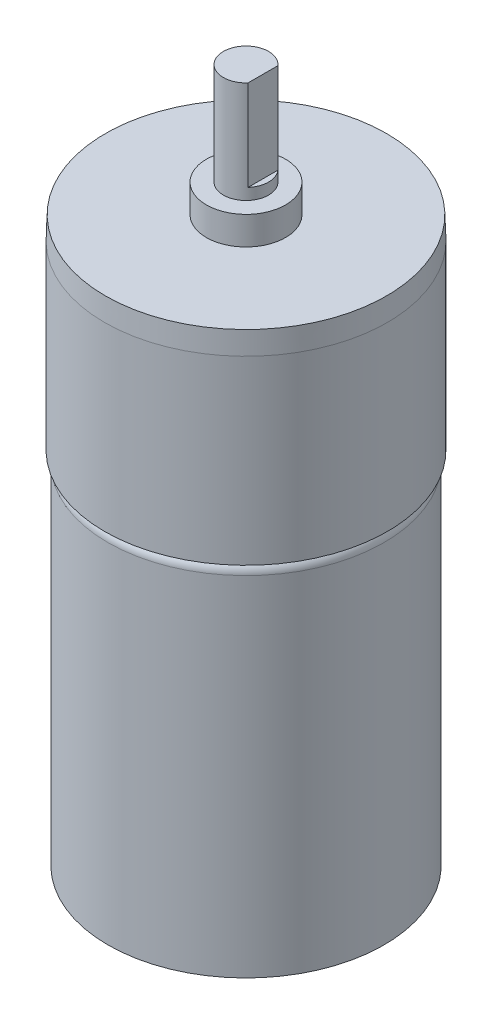
from build123d import *

# Parameters (mm, degrees)
SKETCH1_R                = 12.2
BOSS_EXTRUDE1_DEPTH      = 30.8
BOSS_EXTRUDE1_DEPTH_BACK = 1
FILLET2_R                = 1
SKETCH4_R                = 12.5
BOSS_EXTRUDE2_DEPTH      = 18
CHAMFER5_SIZE            = 2
CHAMFER5_SIZE2           = 0.069841539
SKETCH5_R                = 3.5
BOSS_EXTRUDE3_DEPTH      = 2.5
SKETCH6_R                = 2
BOSS_EXTRUDE4_DEPTH      = 1
BOSS_EXTRUDE6_DEPTH      = 8


with BuildPart() as part:
    # Sketch1 → Boss-Extrude1 (new body, two sides)
    with BuildSketch(Plane(origin=(0, 0, 0), x_dir=(1, 0, 0), z_dir=(0, 1, 0))) as boss_extrude1_sk:
        Circle(SKETCH1_R)
    extrude(amount=BOSS_EXTRUDE1_DEPTH)
    extrude(boss_extrude1_sk.sketch, amount=-BOSS_EXTRUDE1_DEPTH_BACK)

    # Fillet2
    fillet2_edges = [part.edges().sort_by_distance(p)[0] for p in [
        (-12.2, 30.8, 0),
    ]]
    fillet(fillet2_edges, radius=FILLET2_R)

    # Sketch4 → Boss-Extrude2 (add)
    with BuildSketch(Plane(origin=(0, 30.8, 0), x_dir=(1, 0, 0), z_dir=(0, 1, 0))):
        Circle(SKETCH4_R)
    extrude(amount=BOSS_EXTRUDE2_DEPTH)

    # Chamfer5
    chamfer5_edges = [part.edges().sort_by_distance(p)[0] for p in [
        (-12.5, 48.8, 0),
    ]]
    chamfer5_side = [part.faces().sort_by_distance(p)[0] for p in [
        (-12.5, 39.8, 0),
    ]]
    chamfer(chamfer5_edges, length=CHAMFER5_SIZE, length2=CHAMFER5_SIZE2, reference=chamfer5_side[0])

    # Sketch5 → Boss-Extrude3 (add)
    with BuildSketch(Plane(origin=(0, 48.8, 0), x_dir=(1, 0, 0), z_dir=(0, 1, 0))):
        Circle(SKETCH5_R)
    extrude(amount=BOSS_EXTRUDE3_DEPTH)

    # Sketch6 → Boss-Extrude4 (add)
    with BuildSketch(Plane(origin=(0, 51.3, 0), x_dir=(1, 0, 0), z_dir=(0, 1, 0))):
        Circle(SKETCH6_R)
    extrude(amount=BOSS_EXTRUDE4_DEPTH)

    # Sketch12 → Boss-Extrude6 (add)
    with BuildSketch(Plane(origin=(0, 52.3, 0), x_dir=(1, 0, 0), z_dir=(0, 1, 0))):
        with BuildLine():
            Line((1.5, 1.322875656), (1.5, -1.322875656))
            ThreePointArc((1.5, -1.322875656), (-2, 0), (1.5, 1.322875656))
        make_face()
    extrude(amount=BOSS_EXTRUDE6_DEPTH)


solid = part.part
